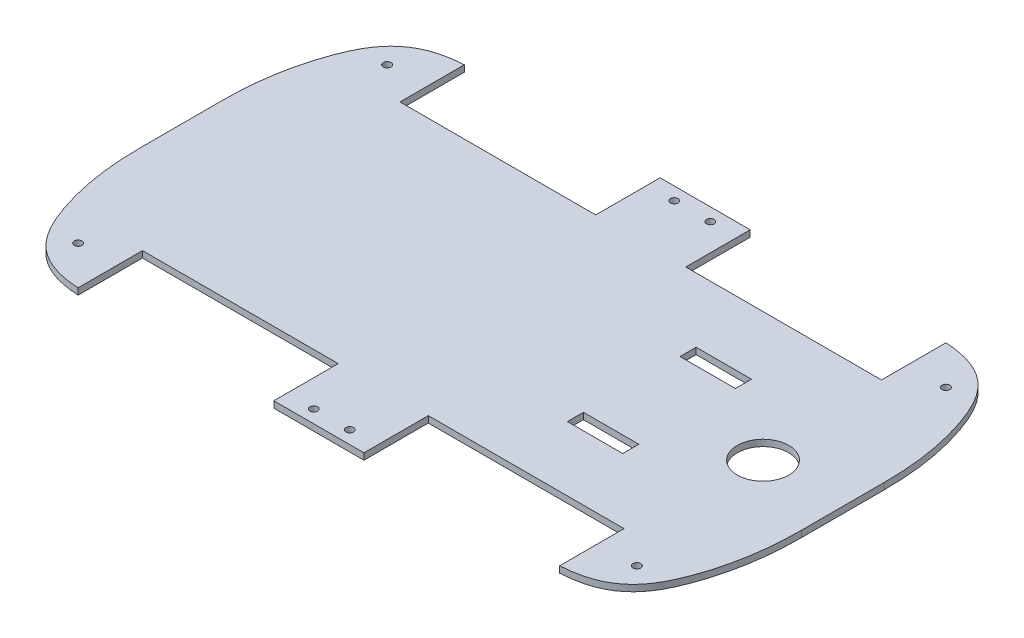
from build123d import *

# Parameters (mm, degrees)
SKETCH_1_R          = 1.5
EXTRUDE_1_DEPTH     = 2.5
SKETCH_2_W          = 21.5
SKETCH_2_H          = 6.25
CUT_EXTRUDE_1_DEPTH = 3.5000001
SKETCH_3_R          = 10
CUT_EXTRUDE_2_DEPTH = 3.5000001


with BuildPart() as part:
    # 草图1 → 凸台-拉伸1 (new body)
    with BuildSketch(Plane(origin=(0, 0, 0), x_dir=(1, 0, 0), z_dir=(0, 1, 0))):
        with BuildLine():
            Line((-128.499999999, -16), (-128.499999999, 16))
            add(Edge.make_bspline(
                [(-93.499999999, 75.000000013), (-111.61760277, 74.009879458), (-123.133759969, 57.24109691), (-128.499999999, 30.447414919), (-128.499999999, 16)],
                knots=[0, 0, 0, 0, 0.426208918, 0.752892545, 0.752892545, 0.752892545, 0.752892545], degree=3))
            Line((-93.499999999, 75.000000013), (-93.499999999, 50))
            Line((-93.499999999, 50), (-17.5, 50))
            Line((-17.5, 50), (-17.5, 75.000000013))
            Line((-17.5, 75.000000013), (17.5, 75.000000013))
            Line((17.5, 75.000000013), (17.5, 50))
            Line((17.5, 50), (93.499999999, 50))
            Line((93.499999999, 50), (93.499999999, 75.000000013))
            add(Edge.make_bspline(
                [(93.499999999, 75.000000013), (111.61760277, 74.009879458), (123.133759969, 57.24109691), (128.499999999, 30.447414919), (128.499999999, 16)],
                knots=[0, 0, 0, 0, 0.426208918, 0.752892545, 0.752892545, 0.752892545, 0.752892545], degree=3))
            Line((128.499999999, 16), (128.499999999, -16))
            add(Edge.make_bspline(
                [(93.499999999, -75.000000013), (111.61760277, -74.009879458), (123.133759969, -57.24109691), (128.499999999, -30.447414919), (128.499999999, -16)],
                knots=[0, 0, 0, 0, 0.426208918, 0.752892545, 0.752892545, 0.752892545, 0.752892545], degree=3))
            Line((93.499999999, -75.000000013), (93.499999999, -50))
            Line((93.499999999, -50), (17.5, -50))
            Line((17.5, -50), (17.5, -75.000000013))
            Line((17.5, -75.000000013), (-17.5, -75.000000013))
            Line((-17.5, -75.000000013), (-17.5, -50))
            Line((-17.5, -50), (-93.499999999, -50))
            Line((-93.499999999, -50), (-93.499999999, -75.000000013))
            add(Edge.make_bspline(
                [(-93.499999999, -75.000000013), (-111.61760277, -74.009879458), (-123.133759969, -57.24109691), (-128.499999999, -30.447414919), (-128.499999999, -16)],
                knots=[0, 0, 0, 0, 0.426208918, 0.752892545, 0.752892545, 0.752892545, 0.752892545], degree=3))
        make_face()
        with Locations((-108.499999999, 60)):
            Circle(SKETCH_1_R, mode=Mode.SUBTRACT)
        with Locations((-108.499999999, -60)):
            Circle(SKETCH_1_R, mode=Mode.SUBTRACT)
        with Locations((108.499999999, -60)):
            Circle(SKETCH_1_R, mode=Mode.SUBTRACT)
        with Locations((108.499999999, 60)):
            Circle(SKETCH_1_R, mode=Mode.SUBTRACT)
        with Locations((7, 70.000000013)):
            Circle(SKETCH_1_R, mode=Mode.SUBTRACT)
        with Locations((-7, 70.000000013)):
            Circle(SKETCH_1_R, mode=Mode.SUBTRACT)
        with Locations((7, -70.000000013)):
            Circle(SKETCH_1_R, mode=Mode.SUBTRACT)
        with Locations((-7, -70.000000013)):
            Circle(SKETCH_1_R, mode=Mode.SUBTRACT)
    extrude(amount=EXTRUDE_1_DEPTH)

    # 草图2 → 切除-拉伸1 (cut, through all)
    with BuildSketch(Plane(origin=(0, 2.5, 0), x_dir=(1, 0, 0), z_dir=(0, 1, 0))):
        with Locations((57.25, 21.875)):
            Rectangle(SKETCH_2_W, SKETCH_2_H)
        with Locations((57.25, -21.875)):
            Rectangle(SKETCH_2_W, SKETCH_2_H)
    extrude(amount=-CUT_EXTRUDE_1_DEPTH, mode=Mode.SUBTRACT)

    # 草图3 → 切除-拉伸2 (cut, through all)
    with BuildSketch(Plane(origin=(0, 2.5, 0), x_dir=(1, 0, 0), z_dir=(0, 1, 0))):
        with Locations((97.499999999, 0)):
            Circle(SKETCH_3_R)
    extrude(amount=-CUT_EXTRUDE_2_DEPTH, mode=Mode.SUBTRACT)


solid = part.part
